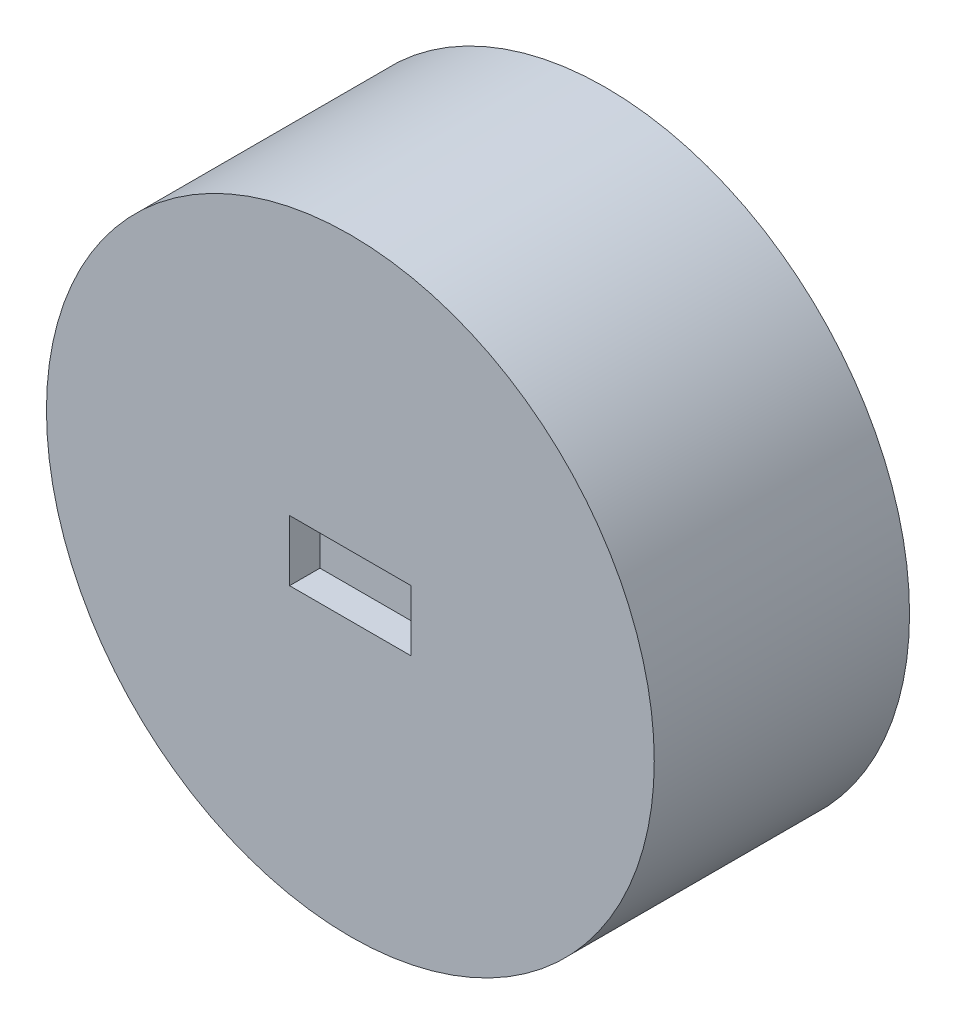
from build123d import *

# Parameters (mm, degrees)
SKETCH1_R           = 50
BOSS_EXTRUDE2_DEPTH = 42
SKETCH2_R           = 4
CUT_EXTRUDE1_DEPTH  = 10
SKETCH3_W           = 20
SKETCH3_H           = 10
CUT_EXTRUDE3_DEPTH  = 5


with BuildPart() as part:
    # Sketch1 → Boss-Extrude2 (new body)
    with BuildSketch(Plane.XY):
        Circle(SKETCH1_R)
    extrude(amount=BOSS_EXTRUDE2_DEPTH)

    # Sketch2 → Cut-Extrude1 (cut)
    with BuildSketch(Plane(origin=(0, 0, 0), x_dir=(-1, 0, 0), z_dir=(0, 0, -1))):
        Circle(SKETCH2_R)
    extrude(amount=-CUT_EXTRUDE1_DEPTH, mode=Mode.SUBTRACT)

    # Sketch3 → Cut-Extrude3 (cut)
    with BuildSketch(Plane.XY.offset(42)):
        Rectangle(SKETCH3_W, SKETCH3_H)
    extrude(amount=-CUT_EXTRUDE3_DEPTH, mode=Mode.SUBTRACT)


solid = part.part
